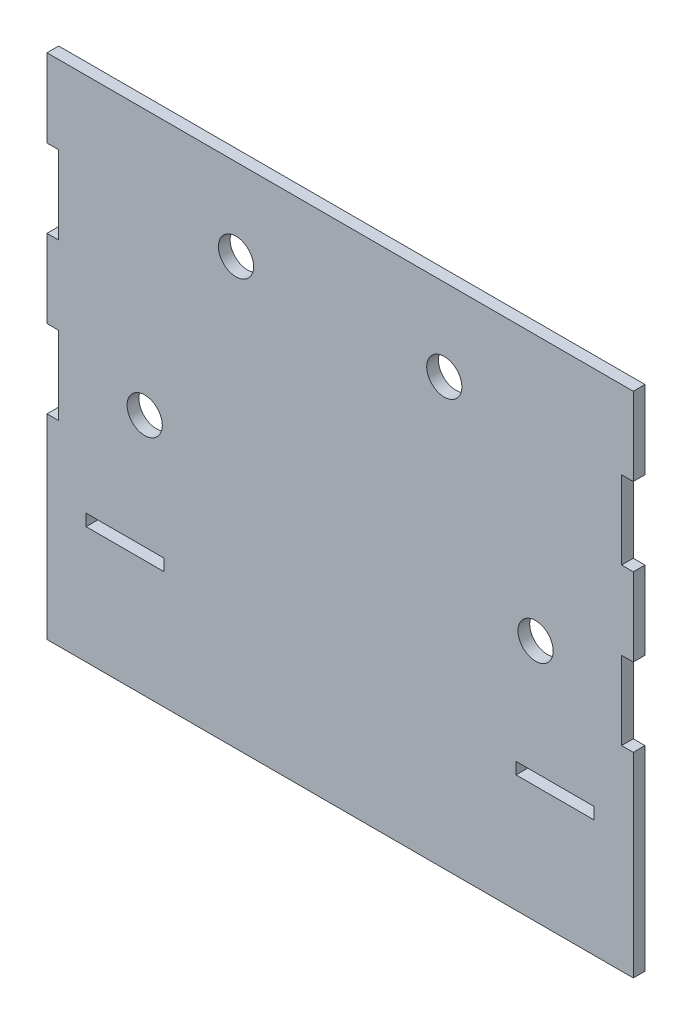
from build123d import *

# Parameters (mm, degrees)
SKETCH1_W           = 150
SKETCH1_H           = 100
BOSS_EXTRUDE1_DEPTH = 3
SKETCH2_W           = 3
SKETCH2_H           = 20
SKETCH2_W_2         = 20
SKETCH2_H_2         = 3
CUT_EXTRUDE1_DEPTH  = 3
SKETCH3_W           = 150
SKETCH3_H           = 3
BOSS_EXTRUDE2_DEPTH = 30
SKETCH5_R           = 4.5
CUT_EXTRUDE2_DEPTH  = 10
SKETCH6_R           = 4.5
CUT_EXTRUDE3_DEPTH  = 10


with BuildPart() as part:
    # Sketch1 → Boss-Extrude1 (new body)
    with BuildSketch(Plane.XY):
        Rectangle(SKETCH1_W, SKETCH1_H)
    extrude(amount=BOSS_EXTRUDE1_DEPTH)

    # Sketch2 → Cut-Extrude1 (cut)
    with BuildSketch(Plane.XY.offset(3)):
        with Locations((73.5, 20)):
            Rectangle(SKETCH2_W, SKETCH2_H)
        with Locations((73.5, -20)):
            Rectangle(SKETCH2_W, SKETCH2_H)
        with Locations((-73.5, -20)):
            Rectangle(SKETCH2_W, SKETCH2_H)
        with Locations((-73.5, 20)):
            Rectangle(SKETCH2_W, SKETCH2_H)
        with Locations((-55, -48.5)):
            Rectangle(SKETCH2_W_2, SKETCH2_H_2)
        with Locations((55, -48.5)):
            Rectangle(SKETCH2_W_2, SKETCH2_H_2)
    extrude(amount=-CUT_EXTRUDE1_DEPTH, mode=Mode.SUBTRACT)

    # Sketch3 → Boss-Extrude2 (add)
    with BuildSketch(Plane.XZ.offset(50)):
        with Locations((0, 1.5)):
            Rectangle(SKETCH3_W, SKETCH3_H)
    extrude(amount=BOSS_EXTRUDE2_DEPTH)

    # Sketch5 → Cut-Extrude2 (cut)
    with BuildSketch(Plane.XY.offset(3)):
        with Locations((50, -17.807715926)):
            Circle(SKETCH5_R)
        with Locations((-50, -17.807715926)):
            Circle(SKETCH5_R)
    extrude(amount=-CUT_EXTRUDE2_DEPTH, mode=Mode.SUBTRACT)

    # Sketch6 → Cut-Extrude3 (cut)
    with BuildSketch(Plane(origin=(0, 0, 0), x_dir=(-1, 0, 0), z_dir=(0, 0, -1))):
        with Locations((26.644067797, 29.026784983)):
            Circle(SKETCH6_R)
        with Locations((-26.644067797, 29.026784983)):
            Circle(SKETCH6_R)
    extrude(amount=-CUT_EXTRUDE3_DEPTH, mode=Mode.SUBTRACT)


solid = part.part
